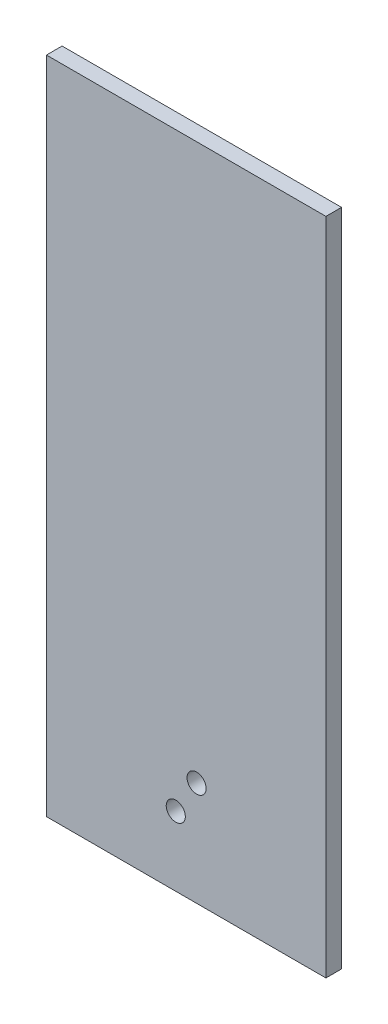
from build123d import *

# Parameters (mm, degrees)
SKETCH1_W           = 161
SKETCH1_H           = 380
BOSS_EXTRUDE1_DEPTH = 9
SKETCH2_R           = 5.5
CUT_EXTRUDE1_DEPTH  = 10


with BuildPart() as part:
    # Sketch1 → Boss-Extrude1 (new body)
    with BuildSketch(Plane.XY):
        Rectangle(SKETCH1_W, SKETCH1_H)
    extrude(amount=BOSS_EXTRUDE1_DEPTH)

    # Sketch2 → Cut-Extrude1 (cut, through all)
    with BuildSketch(Plane.XY.offset(9)):
        with Locations((6, -130)):
            Circle(SKETCH2_R)
        with Locations((-6, -150)):
            Circle(SKETCH2_R)
    extrude(amount=-CUT_EXTRUDE1_DEPTH, mode=Mode.SUBTRACT)


solid = part.part
